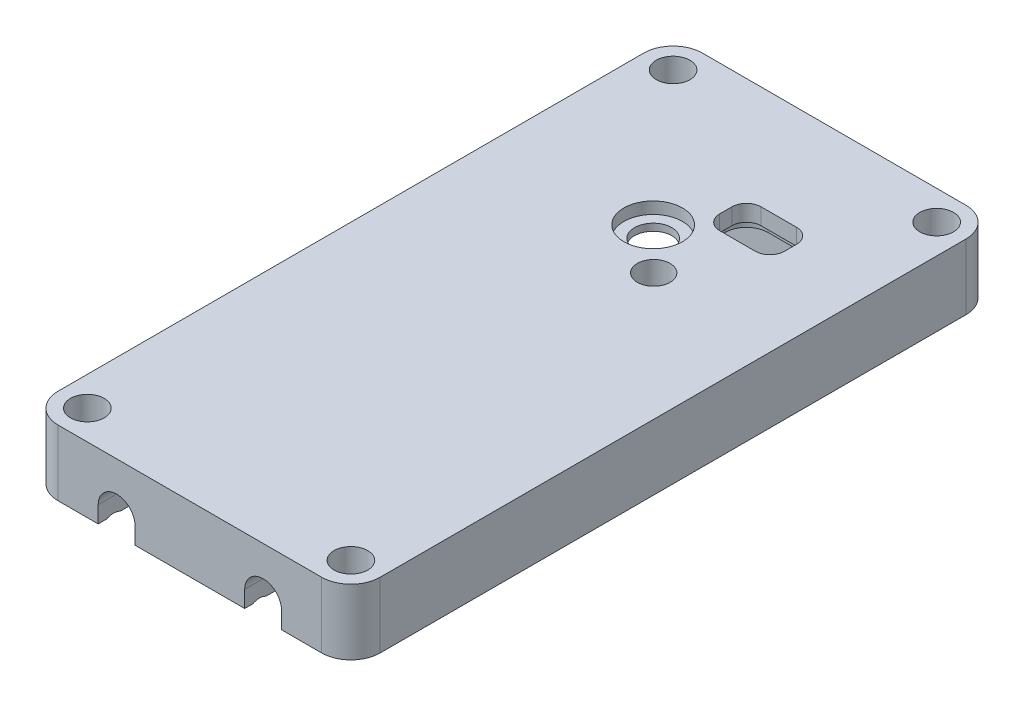
from build123d import *

# Parameters (mm, degrees)
SKETCH1_W             = 34.925
SKETCH1_H             = 69.85
BOSS_EXTRUDE1_DEPTH   = 7.112
FILLET1_R             = 3.175
SKETCH8_R             = 2.38125
BOSS_EXTRUDE2_DEPTH   = 7.112
SKETCH9_R             = 2.0193
CUT_EXTRUDE6_DEPTH    = 8.112
SKETCH12_W            = 28.25399988
SKETCH12_H            = 52.253999886
CUT_EXTRUDE8_DEPTH    = 4.318
FILLET2_R             = 1.5875
SKETCH16_W            = 17.272
SKETCH16_H            = 16.002
BOSS_EXTRUDE3_DEPTH   = 2.0574
CUT_EXTRUDE10_DEPTH   = 70.85
F_6_CLEARANCE_HOLE1_D = 3.6576
SKETCH36_W            = 8.08260004
SKETCH36_H            = 4.035500057
CUT_EXTRUDE17_DEPTH   = 4.318
FILLET3_R             = 1.5875
CUT_EXTRUDE18_DEPTH   = 3.794
SKETCH38_R            = 3.175
CUT_EXTRUDE19_DEPTH   = 1.2446
SKETCH39_R            = 1.778
CUT_EXTRUDE20_DEPTH   = 2.8956
SKETCH40_R            = 1.5875
CUT_EXTRUDE21_DEPTH   = 5.3180001
SKETCH41_R            = 3.175
CUT_EXTRUDE22_DEPTH   = 1.27
SKETCH42_R            = 3.175
CUT_EXTRUDE23_DEPTH   = 0.762
CUT_EXTRUDE24_DEPTH   = 1.016


with BuildPart() as part:
    # Sketch1 → Boss-Extrude1 (new body)
    with BuildSketch(Plane(origin=(0, 0, 0), x_dir=(1, 0, 0), z_dir=(0, 1, 0))):
        Rectangle(SKETCH1_W, SKETCH1_H)
    extrude(amount=BOSS_EXTRUDE1_DEPTH)

    # Fillet1
    fillet1_edges = [part.edges().sort_by_distance(p)[0] for p in [
        (17.4625, 3.556, 34.925),
        (-17.4625, 3.556, 34.925),
        (-17.4625, 3.556, -34.925),
        (17.4625, 3.556, -34.925),
    ]]
    fillet(fillet1_edges, radius=FILLET1_R)

    # Sketch8 → Boss-Extrude2 (add)
    with BuildSketch(Plane(origin=(0, 0, 0), x_dir=(1, 0, 0), z_dir=(0, 1, 0))):
        with Locations((-1.2573, 21.6662)):
            Circle(SKETCH8_R)
    extrude(amount=BOSS_EXTRUDE2_DEPTH)

    # Sketch9 → Cut-Extrude6 (cut, through all)
    with BuildSketch(Plane(origin=(0, 7.112, 0), x_dir=(1, 0, 0), z_dir=(0, 1, 0))):
        with Locations((-0.8255, 16.129)):
            Circle(SKETCH9_R)
    extrude(amount=-CUT_EXTRUDE6_DEPTH, mode=Mode.SUBTRACT)

    # Sketch12 → Cut-Extrude8 (cut)
    with BuildSketch(Plane.XZ):
        Rectangle(SKETCH12_W, SKETCH12_H)
    extrude(amount=-CUT_EXTRUDE8_DEPTH, mode=Mode.SUBTRACT)

    # Fillet2
    fillet2_edges = [part.edges().sort_by_distance(p)[0] for p in [
        (-14.12699994, 2.159, 26.126999943),
        (14.12699994, 2.159, 26.126999943),
        (14.12699994, 2.159, -26.126999943),
        (-14.12699994, 2.159, -26.126999943),
    ]]
    fillet(fillet2_edges, radius=FILLET2_R)

    # Sketch16 → Boss-Extrude3 (add)
    with BuildSketch(Plane.XZ.offset(-4.318)):
        with Locations((-0.847000084, 10.947000013)):
            Rectangle(SKETCH16_W, SKETCH16_H)
    extrude(amount=BOSS_EXTRUDE3_DEPTH)

    # Cut-Sweep1: sweep along a path in Sketch31
    with BuildLine(Plane.XZ) as cut_sweep1_path:
        Line((-12.7, 28.575), (-13.096875, 28.575))
        ThreePointArc((-13.096875, 28.575), (-15.34193903, 27.64506403), (-16.271875, 25.4))
        Line((-16.271875, 25.4), (-16.271875, -25.4))
        ThreePointArc((-16.271875, -25.4), (-15.34193903, -27.64506403), (-13.096875, -28.575))
        Line((-13.096875, -28.575), (-12.7, -28.575))
        ThreePointArc((-12.7, -28.575), (-11.577467985, -29.039967985), (-11.1125, -30.1625))
        Line((-11.1125, -30.1625), (-11.1125, -31.75))
        ThreePointArc((-11.1125, -31.75), (-10.647532015, -32.872532015), (-9.525, -33.3375))
        Line((-9.525, -33.3375), (9.525, -33.3375))
        ThreePointArc((9.525, -33.3375), (10.647532015, -32.872532015), (11.1125, -31.75))
        Line((11.1125, -31.75), (11.1125, -30.1625))
        ThreePointArc((11.1125, -30.1625), (11.577467985, -29.039967985), (12.7, -28.575))
        Line((12.7, -28.575), (13.096875, -28.575))
        ThreePointArc((13.096875, -28.575), (15.34193903, -27.64506403), (16.271875, -25.4))
        Line((16.271875, -25.4), (16.271875, 25.4))
        ThreePointArc((16.271875, 25.4), (15.34193903, 27.64506403), (13.096875, 28.575))
        Line((13.096875, 28.575), (12.7, 28.575))
        ThreePointArc((12.7, 28.575), (11.577467985, 29.039967985), (11.1125, 30.1625))
        Line((11.1125, 30.1625), (11.1125, 31.75))
        ThreePointArc((11.1125, 31.75), (10.647532015, 32.872532015), (9.525, 33.3375))
        Line((9.525, 33.3375), (-9.525, 33.3375))
        ThreePointArc((-9.525, 33.3375), (-10.647532015, 32.872532015), (-11.1125, 31.75))
        Line((-11.1125, 31.75), (-11.1125, 30.1625))
        ThreePointArc((-11.1125, 30.1625), (-11.577467985, 29.039967985), (-12.7, 28.575))
    # Sketch32 → Cut-Sweep1 (sweep, cut)
    with BuildSketch(Plane(origin=(0, 0, 0), x_dir=(0, 0, -1), z_dir=(1, 0, 0))):
        with BuildLine():
            Line((-34.067501479, 0), (-32.607498521, 0))
            ThreePointArc((-32.607498521, 0), (-33.3375, 0.1778), (-34.067501479, 0))
        make_face()
    sweep(path=cut_sweep1_path.line, mode=Mode.SUBTRACT)

    # Sketch15 → Cut-Extrude10 (cut, through all)
    with BuildSketch(Plane(origin=(0, 0, -34.925), x_dir=(-1, 0, 0), z_dir=(0, 0, -1))):
        with BuildLine():
            Line((-5.94630002, 0), (-5.94630002, 1.80000002))
            ThreePointArc((-5.94630002, 1.80000002), (-7.94630002, 3.80000002), (-9.94630002, 1.80000002))
            Line((-9.94630002, 1.80000002), (-9.94630002, 0))
            ThreePointArc((-9.94630002, 0), (-7.94630002, -2), (-5.94630002, 0))
        make_face()
        with BuildLine():
            Line((9.9375, 0), (9.9375, 1.80000002))
            ThreePointArc((9.9375, 1.80000002), (7.9375, 3.80000002), (5.9375, 1.80000002))
            Line((5.9375, 1.80000002), (5.9375, 0))
            ThreePointArc((5.9375, 0), (7.9375, -2), (9.9375, 0))
        make_face()
    extrude(amount=-CUT_EXTRUDE10_DEPTH, mode=Mode.SUBTRACT)

    # #6 Clearance Hole1 (through all)
    with Locations(Plane(origin=(0, 7.112, 0), x_dir=(1, 0, 0), z_dir=(0, 1, 0))):
        with Locations((-14.2875, -31.75), (-14.2875, 31.75), (14.2875, 31.75), (14.2875, -31.75)):
            Hole(F_6_CLEARANCE_HOLE1_D / 2)

    # Sketch36 → Cut-Extrude17 (cut)
    with BuildSketch(Plane.XZ):
        with Locations((0, 28.144749972)):
            Rectangle(SKETCH36_W, SKETCH36_H)
    extrude(amount=-CUT_EXTRUDE17_DEPTH, mode=Mode.SUBTRACT)

    # Fillet3
    fillet3_edges = [part.edges().sort_by_distance(p)[0] for p in [
        (4.04130002, 2.159, 30.1625),
        (4.04130002, 2.159, 26.126999943),
        (-4.04130002, 2.159, 26.126999943),
        (-4.04130002, 2.159, 30.1625),
    ]]
    fillet(fillet3_edges, radius=FILLET3_R)

    # Sketch37 → Cut-Extrude18 (cut, through all)
    with BuildSketch(Plane.XZ.offset(-4.318)):
        with BuildLine():
            Line((7.187867925, -23.670967928), (3.336931955, -23.670967928))
            ThreePointArc((3.336931955, -23.670967928), (2.21439994, -23.205999943), (1.749431955, -22.083467928))
            Line((1.749431955, -22.083467928), (1.749431955, -20.772531958))
            ThreePointArc((1.749431955, -20.772531958), (2.21439994, -19.649999943), (3.336931955, -19.185031958))
            Line((3.336931955, -19.185031958), (7.187867925, -19.185031958))
            ThreePointArc((7.187867925, -19.185031958), (8.31039994, -19.649999943), (8.775367925, -20.772531958))
            Line((8.775367925, -20.772531958), (8.775367925, -22.083467928))
            ThreePointArc((8.775367925, -22.083467928), (8.31039994, -23.205999943), (7.187867925, -23.670967928))
        make_face()
    extrude(amount=-CUT_EXTRUDE18_DEPTH, mode=Mode.SUBTRACT)

    # Sketch38 → Cut-Extrude19 (cut)
    with BuildSketch(Plane.XZ.offset(-4.318)):
        with Locations((-8.72949994, -1.425499943)):
            Circle(SKETCH38_R)
    extrude(amount=-CUT_EXTRUDE19_DEPTH, mode=Mode.SUBTRACT)

    # Sketch39 → Cut-Extrude20 (cut)
    with BuildSketch(Plane.XZ.offset(-4.318)):
        with Locations((3.71299994, -11.648999943)):
            Circle(SKETCH39_R)
    extrude(amount=-CUT_EXTRUDE20_DEPTH, mode=Mode.SUBTRACT)

    # Sketch40 → Cut-Extrude21 (cut, through all)
    with BuildSketch(Plane.XZ.offset(-4.318)):
        with Locations((13.004467925, 25.004467928)):
            Circle(SKETCH40_R)
        with Locations((13.004467925, -25.004467928)):
            Circle(SKETCH40_R)
        with Locations((-13.004467925, -25.004467928)):
            Circle(SKETCH40_R)
        with Locations((-13.004467925, 25.004467928)):
            Circle(SKETCH40_R)
    extrude(amount=CUT_EXTRUDE21_DEPTH, mode=Mode.SUBTRACT)

    # Sketch41 → Cut-Extrude22 (cut)
    with BuildSketch(Plane(origin=(0, 7.112, 0), x_dir=(1, 0, 0), z_dir=(0, 1, 0))):
        with Locations((-0.8255, 16.129)):
            Circle(SKETCH41_R)
    extrude(amount=-CUT_EXTRUDE22_DEPTH, mode=Mode.SUBTRACT)

    # Sketch42 → Cut-Extrude23 (cut)
    with BuildSketch(Plane.XZ.offset(-4.318)):
        with Locations((-0.8255, -16.129)):
            Circle(SKETCH42_R)
    extrude(amount=-CUT_EXTRUDE23_DEPTH, mode=Mode.SUBTRACT)

    # Sketch43 → Cut-Extrude24 (cut)
    with BuildSketch(Plane.XZ.offset(-4.318)):
        with BuildLine():
            Line((0.987431955, -20.772531958), (0.987431955, -22.083467928))
            ThreePointArc((0.987431955, -22.083467928), (1.675584573, -23.74481531), (3.336931955, -24.432967928))
            Line((3.336931955, -24.432967928), (7.187867925, -24.432967928))
            ThreePointArc((7.187867925, -24.432967928), (8.849215307, -23.74481531), (9.537367925, -22.083467928))
            Line((9.537367925, -22.083467928), (9.537367925, -20.772531958))
            ThreePointArc((9.537367925, -20.772531958), (8.849215307, -19.111184576), (7.187867925, -18.423031958))
            Line((7.187867925, -18.423031958), (3.336931955, -18.423031958))
            ThreePointArc((3.336931955, -18.423031958), (1.675584573, -19.111184576), (0.987431955, -20.772531958))
        make_face()
    extrude(amount=-CUT_EXTRUDE24_DEPTH, mode=Mode.SUBTRACT)


solid = part.part
